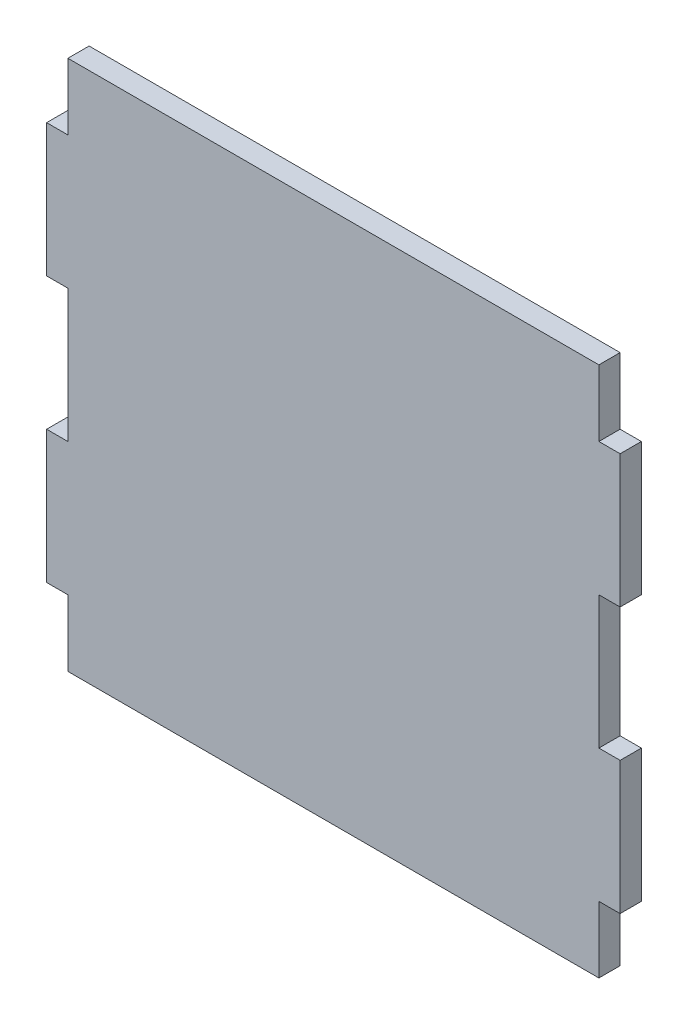
from build123d import *

# Parameters (mm, degrees)
BOSS_EXTRUDE1_DEPTH = 4


with BuildPart() as part:
    # Sketch1 → Boss-Extrude1 (new body)
    with BuildSketch(Plane.XY):
        Polygon((0, 0), (100, 0), (100, -12.5), (104, -12.5), (104, -37.5), (100, -37.5), (100, -62.5), (104, -62.5), (104, -87.5), (100, -87.5), (100, -100), (0, -100), (0, -87.5), (-4, -87.5), (-4, -62.5), (0, -62.5), (0, -37.5), (-4, -37.5), (-4, -12.5), (0, -12.5), align=None)
    extrude(amount=BOSS_EXTRUDE1_DEPTH)


solid = part.part
